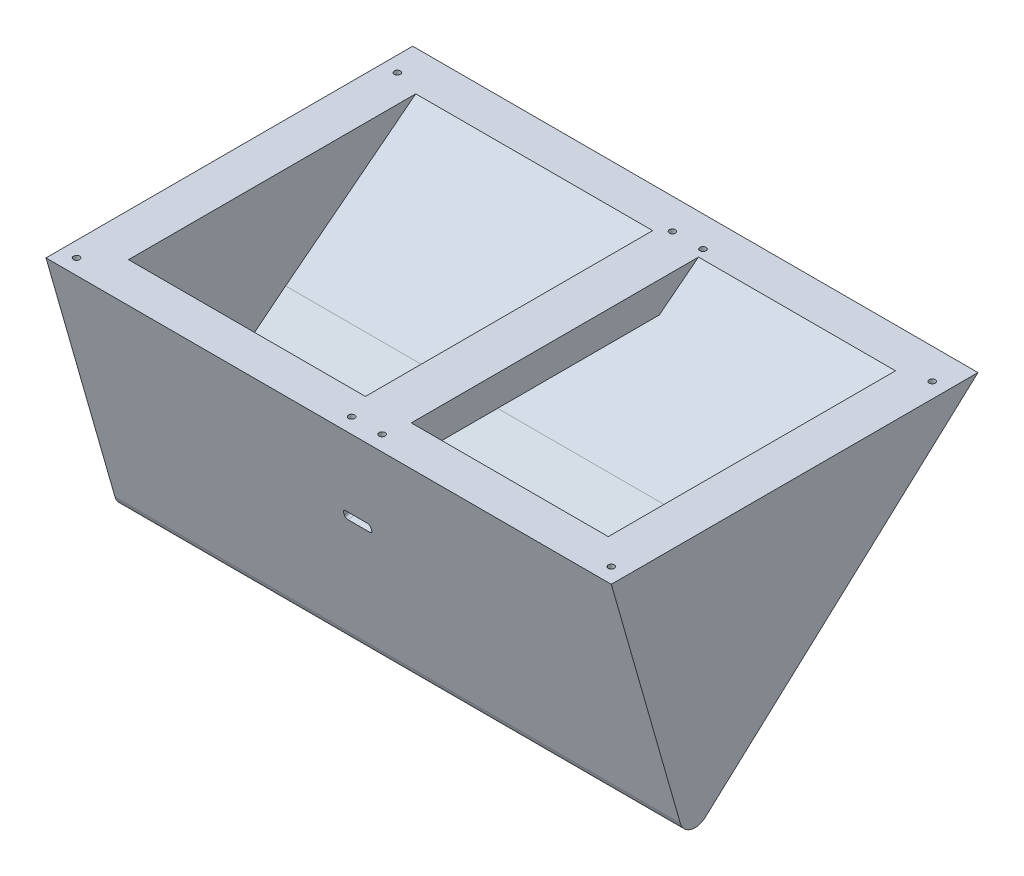
from build123d import *

# Parameters (mm, degrees)
SKETCH1_W           = 185
SKETCH1_H           = 120
BOSS_EXTRUDE1_DEPTH = 10
BOSS_EXTRUDE2_DEPTH = 14
BOSS_EXTRUDE3_DEPTH = 157
BOSS_EXTRUDE4_DEPTH = 14
SKETCH6_W           = 120
SKETCH6_H           = 10
CUT_EXTRUDE1_DEPTH  = 300
SKETCH7_W           = 15
SKETCH7_H           = 94
BOSS_EXTRUDE5_DEPTH = 10
SKETCH8_R           = 1
CUT_EXTRUDE2_DEPTH  = 4
SKETCH9_R           = 1
CUT_EXTRUDE3_DEPTH  = 4
FILLET1_R           = 5
SKETCH10_W          = 8.94
SKETCH10_H          = 3.16
CUT_EXTRUDE4_DEPTH  = 13
FILLET2_R           = 1
SKETCH12_W          = 18.3
SKETCH12_H          = 2
CUT_EXTRUDE6_DEPTH  = 13
SKETCH13_W          = 18.3
SKETCH13_H          = 2
BOSS_EXTRUDE6_DEPTH = 7.89


with BuildPart() as part:
    # Sketch1 → Boss-Extrude1 (new body)
    with BuildSketch(Plane(origin=(0, 0, 0), x_dir=(1, 0, 0), z_dir=(0, 1, 0))):
        Rectangle(SKETCH1_W, SKETCH1_H)
    extrude(amount=BOSS_EXTRUDE1_DEPTH)

    # Sketch3 → Boss-Extrude2 (add)
    with BuildSketch(Plane(origin=(92.5, 0, 0), x_dir=(0, 0, -1), z_dir=(1, 0, 0))):
        Polygon((60, 0), (-35.195789495, -86.829236424), (-60, 0), align=None)
    extrude(amount=-BOSS_EXTRUDE2_DEPTH)

    # Sketch4 → Boss-Extrude3 (add)
    with BuildSketch(Plane.ZY.offset(-78.5)):
        Polygon((35.141852327, -39.693461507), (47, 0), (60, 0), (35.195789495, -86.829236424), (-60, 0), (-47, 0), (-4.415483527, -33.157236801), (31.435973084, -61.614600076), align=None)
    extrude(amount=BOSS_EXTRUDE3_DEPTH)

    # Sketch5 → Boss-Extrude4 (add)
    with BuildSketch(Plane.ZY.offset(78.5)):
        Polygon((60, 0), (-60, 0), (35.195789495, -86.829236424), align=None)
    extrude(amount=BOSS_EXTRUDE4_DEPTH)

    # Sketch6 → Cut-Extrude1 (cut)
    with BuildSketch(Plane.ZY.offset(92.5)):
        with Locations((0, 5)):
            Rectangle(SKETCH6_W, SKETCH6_H)
    extrude(amount=-CUT_EXTRUDE1_DEPTH, mode=Mode.SUBTRACT)

    # Sketch7 → Boss-Extrude5 (add)
    with BuildSketch(Plane(origin=(0, 0, 0), x_dir=(1, 0, 0), z_dir=(0, 1, 0))):
        with Locations((6.531892019, 0)):
            Rectangle(SKETCH7_W, SKETCH7_H)
    extrude(amount=-BOSS_EXTRUDE5_DEPTH)

    # Sketch8 → Cut-Extrude2 (cut)
    with BuildSketch(Plane(origin=(0, 0, 0), x_dir=(1, 0, 0), z_dir=(0, 1, 0))):
        with Locations((87.5, -55)):
            Circle(SKETCH8_R)
        with Locations((-87.5, -55)):
            Circle(SKETCH8_R)
        with Locations((12.5, -55)):
            Circle(SKETCH8_R)
        with Locations((2.5, -55)):
            Circle(SKETCH8_R)
    extrude(amount=-CUT_EXTRUDE2_DEPTH, mode=Mode.SUBTRACT)

    # Sketch9 → Cut-Extrude3 (cut)
    with BuildSketch(Plane(origin=(0, 0, 0), x_dir=(1, 0, 0), z_dir=(0, 1, 0))):
        with Locations((87.5, 50)):
            Circle(SKETCH9_R)
        with Locations((-87.5, 50)):
            Circle(SKETCH9_R)
        with Locations((12.5, 50)):
            Circle(SKETCH9_R)
        with Locations((2.5, 50)):
            Circle(SKETCH9_R)
    extrude(amount=-CUT_EXTRUDE3_DEPTH, mode=Mode.SUBTRACT)

    # Fillet1
    fillet1_edges = [part.edges().sort_by_distance(p)[0] for p in [
        (0, -86.829236424, 35.195789495),
    ]]
    fillet(fillet1_edges, radius=FILLET1_R)

    # Sketch10 → Cut-Extrude4 (cut)
    with BuildSketch(Plane(origin=(0, -15.846809365, 55.473096258), x_dir=(1, 0, 0), z_dir=(0, -0.274678714, 0.961536065))):
        with Locations((0, -18.026592613)):
            Rectangle(SKETCH10_W, SKETCH10_H)
    extrude(amount=-CUT_EXTRUDE4_DEPTH, mode=Mode.SUBTRACT)

    # Fillet2
    fillet2_edges = [part.edges().sort_by_distance(p)[0] for p in [
        (4.47, -29.895487229, 44.775936137),
        (4.47, -32.92871232, 43.889647284),
        (-4.47, -32.92871232, 43.889647284),
        (-4.47, -29.895487229, 44.775936137),
    ]]
    fillet(fillet2_edges, radius=FILLET2_R)

    # Sketch12 → Cut-Extrude6 (cut)
    with BuildSketch(Plane(origin=(0, -15.846809365, 55.473096258), x_dir=(1, 0, 0), z_dir=(0, -0.274678714, 0.961536065))):
        with Locations((0, -20.606592613)):
            Rectangle(SKETCH12_W, SKETCH12_H)
    extrude(amount=-CUT_EXTRUDE6_DEPTH, mode=Mode.SUBTRACT)

    # Sketch13 → Boss-Extrude6 (add)
    with BuildSketch(Plane(origin=(0, -15.846809365, 55.473096258), x_dir=(1, 0, 0), z_dir=(0, -0.274678714, 0.961536065))):
        with Locations((0, -20.606592613)):
            Rectangle(SKETCH13_W, SKETCH13_H)
    extrude(amount=-BOSS_EXTRUDE6_DEPTH)


solid = part.part
